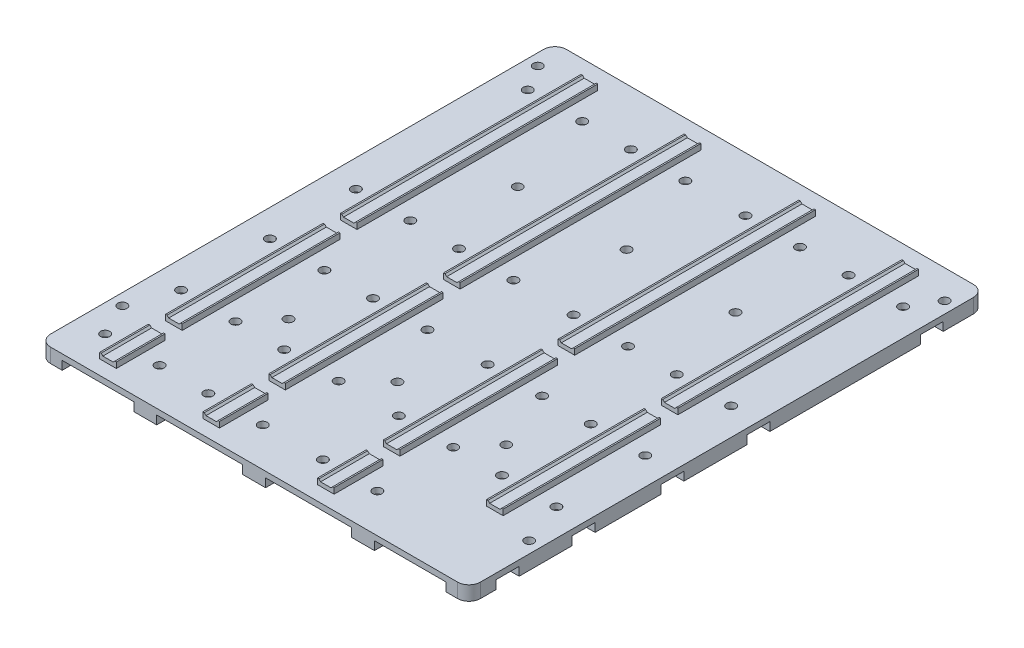
from build123d import *

# Parameters (mm, degrees)
SKETCH1_W           = 150
SKETCH1_H           = 180
BOSS_EXTRUDE1_DEPTH = 2
SKETCH2_W           = 5.8
SKETCH2_H           = 55
SKETCH2_H_2         = 17
SKETCH2_H_3         = 84
BOSS_EXTRUDE2_DEPTH = 2
SKETCH3_R           = 1.6
CUT_EXTRUDE1_DEPTH  = 3
CUT_EXTRUDE2_DEPTH  = 176
SKETCH5_W           = 8
SKETCH5_H           = 3
BOSS_EXTRUDE3_DEPTH = 180
SKETCH6_R           = 1.6
CUT_EXTRUDE3_DEPTH  = 10
SKETCH7_W           = 17.667286443
SKETCH7_H           = 8
SKETCH7_W_2         = 22.845070825
CUT_EXTRUDE4_DEPTH  = 3
FILLET1_R           = 4


with BuildPart() as part:
    # Sketch1 → Boss-Extrude1 (new body)
    with BuildSketch(Plane(origin=(0, 0, 0), x_dir=(1, 0, 0), z_dir=(0, 1, 0))):
        Rectangle(SKETCH1_W, SKETCH1_H)
    extrude(amount=BOSS_EXTRUDE1_DEPTH)

    # Sketch2 → Boss-Extrude2 (add)
    with BuildSketch(Plane(origin=(0, 2, 0), x_dir=(1, 0, 0), z_dir=(0, 1, 0))):
        with Locations((-56, -34.5)):
            Rectangle(SKETCH2_W, SKETCH2_H)
        with Locations((-56, -76.5)):
            Rectangle(SKETCH2_W, SKETCH2_H_2)
        with Locations((-20, -34.5)):
            Rectangle(SKETCH2_W, SKETCH2_H)
        with Locations((-20, -76.5)):
            Rectangle(SKETCH2_W, SKETCH2_H_2)
        with Locations((20, -34.5)):
            Rectangle(SKETCH2_W, SKETCH2_H)
        with Locations((20, -76.5)):
            Rectangle(SKETCH2_W, SKETCH2_H_2)
        with Locations((56, -34.5)):
            Rectangle(SKETCH2_W, SKETCH2_H)
        with Locations((-56, 41)):
            Rectangle(SKETCH2_W, SKETCH2_H_3)
        with Locations((-20, 41)):
            Rectangle(SKETCH2_W, SKETCH2_H_3)
        with Locations((20, 41)):
            Rectangle(SKETCH2_W, SKETCH2_H_3)
        with Locations((56, 41)):
            Rectangle(SKETCH2_W, SKETCH2_H_3)
    extrude(amount=BOSS_EXTRUDE2_DEPTH)

    # Sketch3 → Cut-Extrude1 (cut, through all)
    with BuildSketch(Plane(origin=(0, 2, 0), x_dir=(1, 0, 0), z_dir=(0, 1, 0))):
        with Locations((-65.5, -76.5)):
            Circle(SKETCH3_R)
        with Locations((-46.5, -76.5)):
            Circle(SKETCH3_R)
        with Locations((-29.5, -76.5)):
            Circle(SKETCH3_R)
        with Locations((-10.5, -76.5)):
            Circle(SKETCH3_R)
        with Locations((10.5, -76.5)):
            Circle(SKETCH3_R)
        with Locations((29.5, -76.5)):
            Circle(SKETCH3_R)
        with Locations((-65.5, -50)):
            Circle(SKETCH3_R)
        with Locations((-46.5, -50)):
            Circle(SKETCH3_R)
        with Locations((-29.5, -50)):
            Circle(SKETCH3_R)
        with Locations((-10.5, -50)):
            Circle(SKETCH3_R)
        with Locations((10.5, -50)):
            Circle(SKETCH3_R)
        with Locations((29.5, -50)):
            Circle(SKETCH3_R)
        with Locations((46.5, -50)):
            Circle(SKETCH3_R)
        with Locations((65.5, -50)):
            Circle(SKETCH3_R)
        with Locations((65.5, 11)):
            Circle(SKETCH3_R)
        with Locations((-65.5, 11)):
            Circle(SKETCH3_R)
        with Locations((10.5, 11)):
            Circle(SKETCH3_R)
        with Locations((-29.5, 11)):
            Circle(SKETCH3_R)
        with Locations((-46.5, 11)):
            Circle(SKETCH3_R)
        with Locations((46.5, 11)):
            Circle(SKETCH3_R)
        with Locations((29.5, 11)):
            Circle(SKETCH3_R)
        with Locations((-10.5, 11)):
            Circle(SKETCH3_R)
        with Locations((10.5, 71)):
            Circle(SKETCH3_R)
        with Locations((65.5, 71)):
            Circle(SKETCH3_R)
        with Locations((29.5, 71)):
            Circle(SKETCH3_R)
        with Locations((-46.5, 71)):
            Circle(SKETCH3_R)
        with Locations((-65.5, 71)):
            Circle(SKETCH3_R)
        with Locations((-29.5, 71)):
            Circle(SKETCH3_R)
        with Locations((-10.5, 71)):
            Circle(SKETCH3_R)
        with Locations((46.5, 71)):
            Circle(SKETCH3_R)
        with Locations((-65.5, -19)):
            Circle(SKETCH3_R)
        with Locations((10.5, -19)):
            Circle(SKETCH3_R)
        with Locations((65.5, -19)):
            Circle(SKETCH3_R)
        with Locations((-46.5, -19)):
            Circle(SKETCH3_R)
        with Locations((-29.5, -19)):
            Circle(SKETCH3_R)
        with Locations((29.5, -19)):
            Circle(SKETCH3_R)
        with Locations((46.5, -19)):
            Circle(SKETCH3_R)
        with Locations((-10.5, -19)):
            Circle(SKETCH3_R)
    extrude(amount=-CUT_EXTRUDE1_DEPTH, mode=Mode.SUBTRACT)

    # Sketch4 → Cut-Extrude2 (cut, through all)
    with BuildSketch(Plane.XY.offset(85)):
        Polygon((-53.6, 4), (-58.4, 4), (-57.8, 3.4), (-54.2, 3.4), align=None)
        Polygon((-18.2, 3.4), (-17.6, 4), (-22.4, 4), (-21.8, 3.4), align=None)
        Polygon((22.4, 4), (21.8, 3.4), (18.2, 3.4), (17.6, 4), align=None)
        Polygon((58.4, 4), (57.8, 3.4), (54.2, 3.4), (53.6, 4), align=None)
    extrude(amount=-CUT_EXTRUDE2_DEPTH, mode=Mode.SUBTRACT)

    # Sketch5 → Boss-Extrude3 (add, through all)
    with BuildSketch(Plane.XY.offset(90)):
        with Locations((-71, -1.5)):
            Rectangle(SKETCH5_W, SKETCH5_H)
        with Locations((71, -1.5)):
            Rectangle(SKETCH5_W, SKETCH5_H)
        with Locations((-38, -1.5)):
            Rectangle(SKETCH5_W, SKETCH5_H)
        with Locations((0, -1.5)):
            Rectangle(SKETCH5_W, SKETCH5_H)
        with Locations((38, -1.5)):
            Rectangle(SKETCH5_W, SKETCH5_H)
    extrude(amount=-BOSS_EXTRUDE3_DEPTH)

    # Sketch6 → Cut-Extrude3 (cut)
    with BuildSketch(Plane(origin=(0, 2, 0), x_dir=(1, 0, 0), z_dir=(0, 1, 0))):
        with Locations((-38, -40)):
            Circle(SKETCH6_R)
        with Locations((38, -40)):
            Circle(SKETCH6_R)
        with Locations((0, -40)):
            Circle(SKETCH6_R)
        with Locations((-38, 40)):
            Circle(SKETCH6_R)
        with Locations((0, 40)):
            Circle(SKETCH6_R)
        with Locations((38, 40)):
            Circle(SKETCH6_R)
        with Locations((-71, -65)):
            Circle(SKETCH6_R)
        with Locations((71, -65)):
            Circle(SKETCH6_R)
        with Locations((71, 80)):
            Circle(SKETCH6_R)
        with Locations((-71, 80)):
            Circle(SKETCH6_R)
    extrude(amount=-CUT_EXTRUDE3_DEPTH, mode=Mode.SUBTRACT)

    # Sketch7 → Cut-Extrude4 (cut)
    with BuildSketch(Plane.XZ.offset(3)):
        with Locations((-66.166356779, 76.5)):
            Rectangle(SKETCH7_W, SKETCH7_H)
        with Locations((63.577464588, 76.5)):
            Rectangle(SKETCH7_W_2, SKETCH7_H)
        with Locations((-66.166356779, 50)):
            Rectangle(SKETCH7_W, SKETCH7_H)
        with Locations((63.577464588, 50)):
            Rectangle(SKETCH7_W_2, SKETCH7_H)
        with Locations((-66.166356779, 19)):
            Rectangle(SKETCH7_W, SKETCH7_H)
        with Locations((63.577464588, 19)):
            Rectangle(SKETCH7_W_2, SKETCH7_H)
        with Locations((-66.166356779, -11)):
            Rectangle(SKETCH7_W, SKETCH7_H)
        with Locations((63.577464588, -11)):
            Rectangle(SKETCH7_W_2, SKETCH7_H)
        with Locations((-66.166356779, -71.5)):
            Rectangle(SKETCH7_W, SKETCH7_H)
        with Locations((63.577464588, -71.5)):
            Rectangle(SKETCH7_W_2, SKETCH7_H)
    extrude(amount=-CUT_EXTRUDE4_DEPTH, mode=Mode.SUBTRACT)

    # Fillet1
    fillet1_edges = [part.edges().sort_by_distance(p)[0] for p in [
        (75, -0.5, 90),
        (-75, -0.5, 90),
        (-75, -0.5, -90),
        (75, -0.5, -90),
    ]]
    fillet(fillet1_edges, radius=FILLET1_R)


solid = part.part
